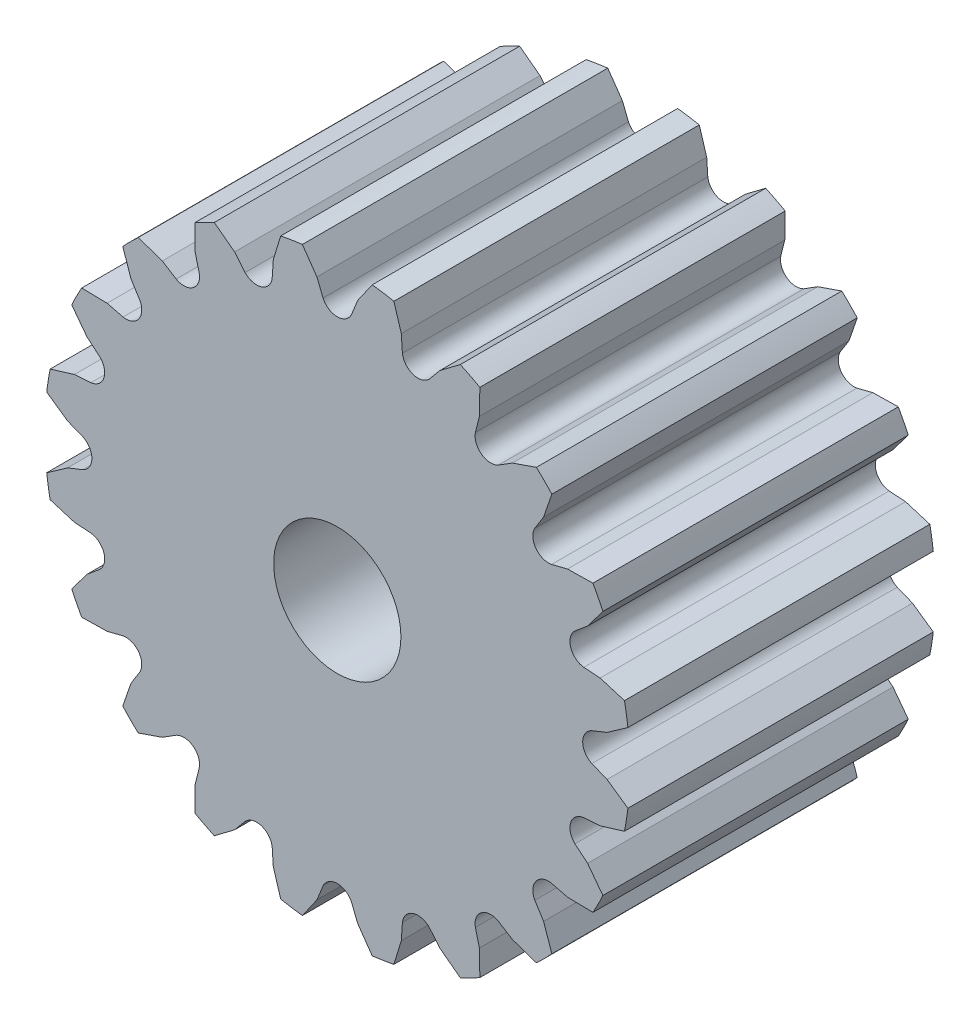
from build123d import *

# Parameters (mm, degrees)
SKETCH1_R           = 11.5
SKETCH1_R_2         = 2.5
BOSS_EXTRUDE1_DEPTH = 12
CUT_EXTRUDE1_DEPTH  = 12
CIRPATTERN1_COUNT   = 20


with BuildPart() as part:
    # Sketch1 → Boss-Extrude1 (new body)
    with BuildSketch(Plane.XY):
        Circle(SKETCH1_R)
        Circle(SKETCH1_R_2, mode=Mode.SUBTRACT)
    extrude(amount=BOSS_EXTRUDE1_DEPTH)

    # Sketch2 → Cut-Extrude1 (cut)
    with BuildSketch(Plane.XY.offset(12)):
        with BuildLine():
            Line((0, 11.6), (1.5, 11.6))
            Line((1.5, 11.6), (0.8, 10.6))
            Line((0.8, 10.6), (0.559317479, 10))
            ThreePointArc((0.559317479, 10), (0, 9.642447684), (-0.559317479, 10))
            Line((-0.559317479, 10), (-0.8, 10.6))
            Line((-0.8, 10.6), (-1.5, 11.6))
            Line((-1.5, 11.6), (0, 11.6))
        make_face()
    cut_extrude1 = extrude(amount=-CUT_EXTRUDE1_DEPTH, mode=Mode.SUBTRACT)

    # CirPattern1: Cut-Extrude1 ×20 about axis
    cirpattern1_axis = Axis((0, 0, 0), (0, 0, 1))
    for i in range(1, CIRPATTERN1_COUNT):
        add(cut_extrude1.rotate(cirpattern1_axis, i * 360 / CIRPATTERN1_COUNT), mode=Mode.SUBTRACT)


solid = part.part
